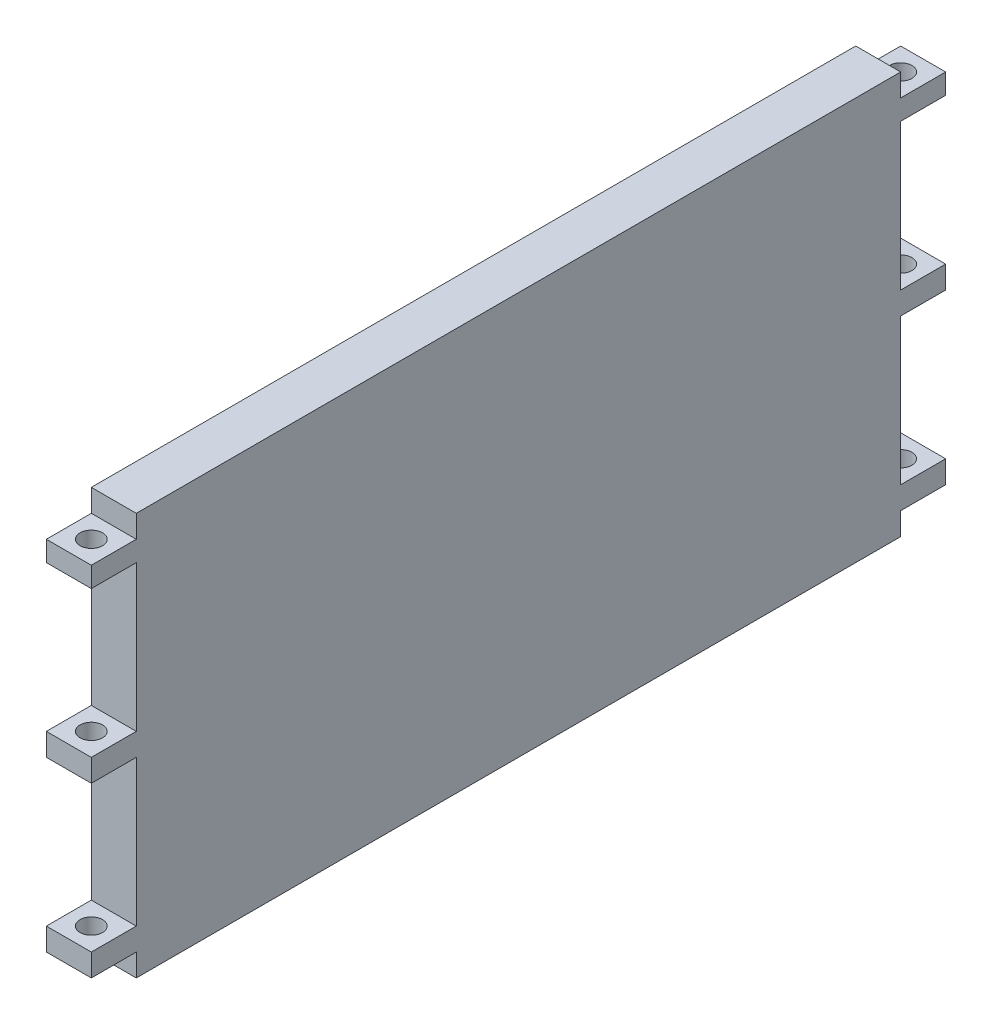
from build123d import *

# Parameters (mm, degrees)
SKETCH1_W           = 380
SKETCH1_H           = 179
BOSS_EXTRUDE1_DEPTH = 20
SKETCH2_W           = 20
SKETCH2_H           = 65
SKETCH2_H_2         = 10
CUT_EXTRUDE1_DEPTH  = 20
SKETCH3_R           = 5
CUT_EXTRUDE2_DEPTH  = 159


with BuildPart() as part:
    # Sketch1 → Boss-Extrude1 (new body)
    with BuildSketch(Plane(origin=(0, 0, 0), x_dir=(0, 0, -1), z_dir=(1, 0, 0))):
        Rectangle(SKETCH1_W, SKETCH1_H)
    extrude(amount=BOSS_EXTRUDE1_DEPTH)

    # Sketch2 → Cut-Extrude1 (cut)
    with BuildSketch(Plane.XY.offset(190)):
        with Locations((10, 38)):
            Rectangle(SKETCH2_W, SKETCH2_H)
        with Locations((10, 84.5)):
            Rectangle(SKETCH2_W, SKETCH2_H_2)
        with Locations((10, -84.5)):
            Rectangle(SKETCH2_W, SKETCH2_H_2)
        with Locations((10, -37)):
            Rectangle(SKETCH2_W, SKETCH2_H)
    cut_extrude1 = extrude(amount=-CUT_EXTRUDE1_DEPTH, mode=Mode.SUBTRACT)

    # Sketch3 → Cut-Extrude2 (cut)
    with BuildSketch(Plane(origin=(0, 79.5, 0), x_dir=(1, 0, 0), z_dir=(0, 1, 0))):
        with Locations((10, -180)):
            Circle(SKETCH3_R)
    cut_extrude2 = extrude(amount=-CUT_EXTRUDE2_DEPTH, mode=Mode.SUBTRACT)

    # Mirror2: Cut-Extrude1, Cut-Extrude2 across plane
    add(cut_extrude1.mirror(Plane.XY), mode=Mode.SUBTRACT)
    add(cut_extrude2.mirror(Plane.XY), mode=Mode.SUBTRACT)


solid = part.part
